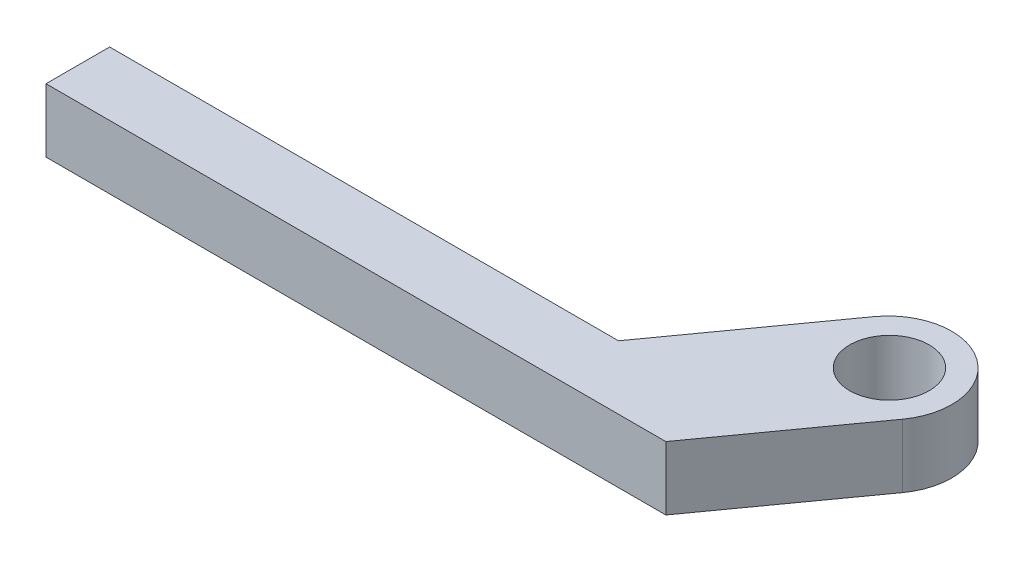
from build123d import *

# Parameters (mm, degrees)
BOSS_EXTRUDE1_DEPTH         = 6.35
F_3_8_16_TAPPED_HOLE1_D     = 7.9375
F_3_8_16_TAPPED_HOLE1_DEPTH = 6.35
F_3_8_16_TAPPED_HOLE1_TIP   = 2.384665582


with BuildPart() as part:
    # Sketch2 → Boss-Extrude1 (new body)
    with BuildSketch(Plane(origin=(0, 0, 0), x_dir=(1, 0, 0), z_dir=(0, 1, 0))):
        with BuildLine():
            Line((-10.638933845, -35.242978242), (0.0062465, -20.425508427))
            ThreePointArc((0.0062465, -20.425508427), (8.868318086, -18.973376472), (10.320450041, -27.835448057))
            Line((10.320450041, -27.835448057), (0.436752504, -41.592978242))
            Line((0.436752504, -41.592978242), (-10.638933845, -41.592978242))
            Line((-10.638933845, -41.592978242), (-61.438933845, -41.592978242))
            Line((-61.438933845, -41.592978242), (-61.438933845, -35.242978242))
            Line((-61.438933845, -35.242978242), (-10.638933845, -35.242978242))
        make_face()
    extrude(amount=BOSS_EXTRUDE1_DEPTH)

    # 3/8-16 Tapped Hole1
    with Locations(Plane(origin=(0, 6.35, 0), x_dir=(1, 0, 0), z_dir=(0, 1, 0))):
        with Locations((5.218739795, -24.053376472)):
            Hole(F_3_8_16_TAPPED_HOLE1_D / 2, depth=F_3_8_16_TAPPED_HOLE1_DEPTH)
            with Locations((0, 0, -(F_3_8_16_TAPPED_HOLE1_DEPTH + F_3_8_16_TAPPED_HOLE1_TIP / 2))):  # 118° drill point
                Cone(0, F_3_8_16_TAPPED_HOLE1_D / 2, F_3_8_16_TAPPED_HOLE1_TIP, mode=Mode.SUBTRACT)


solid = part.part
